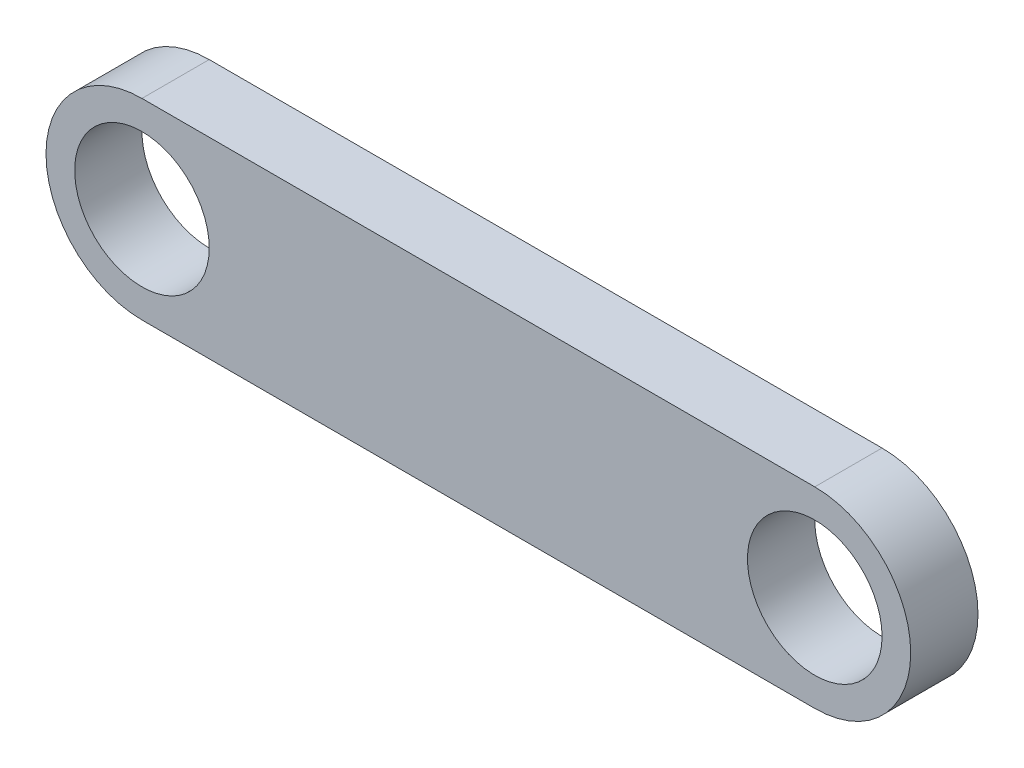
from build123d import *

# Parameters (mm, degrees)
SKETCH1_R           = 5
BOSS_EXTRUDE2_DEPTH = 5


with BuildPart() as part:
    # Sketch1 → Boss-Extrude2 (new body)
    with BuildSketch(Plane.XY):
        with BuildLine():
            Line((0, 7.13028169), (50, 7.13028169))
            ThreePointArc((50, 7.13028169), (57.13028169, 0), (50, -7.13028169))
            Line((50, -7.13028169), (0, -7.13028169))
            ThreePointArc((0, -7.13028169), (-7.13028169, 0), (0, 7.13028169))
        make_face()
        Circle(SKETCH1_R, mode=Mode.SUBTRACT)
        with Locations((50, 0)):
            Circle(SKETCH1_R, mode=Mode.SUBTRACT)
    extrude(amount=BOSS_EXTRUDE2_DEPTH)


solid = part.part
